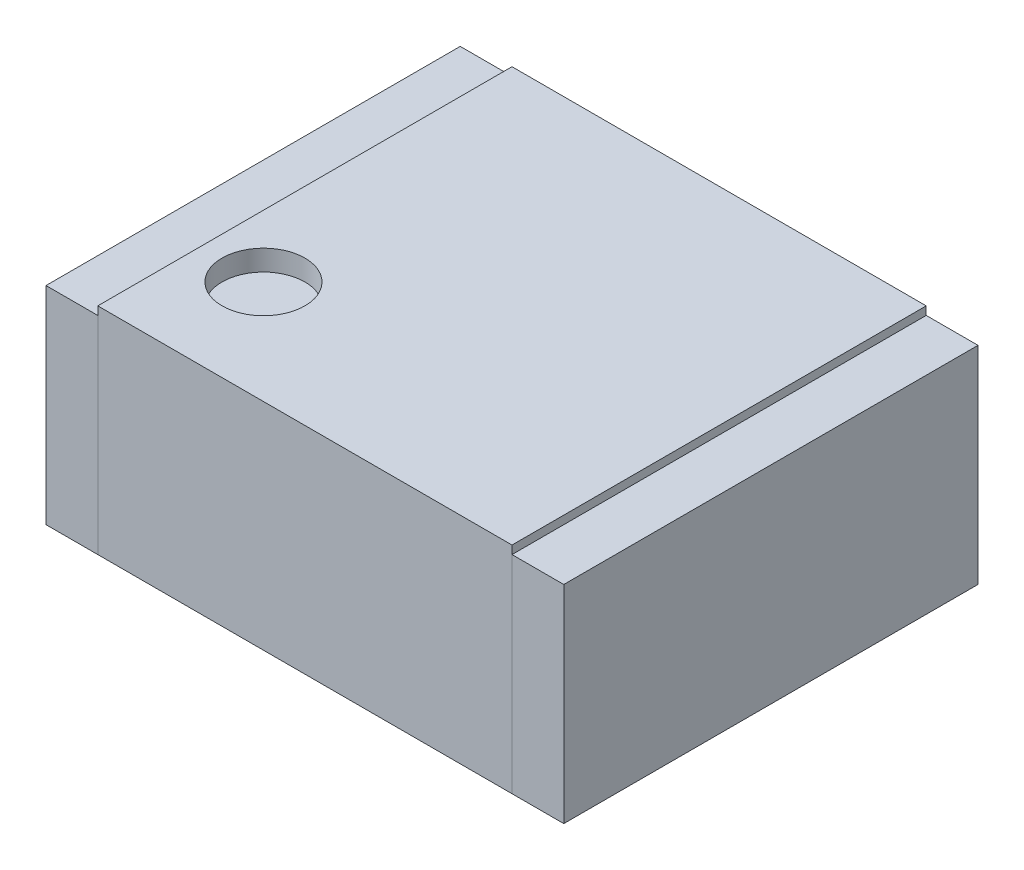
from build123d import *

# Parameters (mm, degrees)
SKETCH1_W             = 2
SKETCH1_H             = 2
BOSS_EXTRUDE1_DEPTH   = 1.04
SKETCH3_W             = 0.25
SKETCH3_H             = 2
BOSS_EXTRUDE2_DEPTH   = 1
BOSS_EXTRUDE2_2_DEPTH = 1
SKETCH4_R             = 0.2
CUT_EXTRUDE1_DEPTH    = 0.1
BOSS_EXTRUDE3_START   = 0.01
BOSS_EXTRUDE3_DEPTH   = 0.1
SKETCH5_W             = 0.3
SKETCH5_H             = 0.2
BOSS_EXTRUDE3_2_DEPTH = 0.1
BOSS_EXTRUDE3_3_DEPTH = 0.1
BOSS_EXTRUDE3_4_DEPTH = 0.1
BOSS_EXTRUDE3_5_DEPTH = 0.1
BOSS_EXTRUDE3_6_DEPTH = 0.1
BOSS_EXTRUDE3_7_DEPTH = 0.1


with BuildPart() as part:
    # Sketch1 → Boss-Extrude1 (new body)
    with BuildSketch(Plane(origin=(0, 0, 0), x_dir=(1, 0, 0), z_dir=(0, 1, 0))):
        Rectangle(SKETCH1_W, SKETCH1_H)
    extrude(amount=BOSS_EXTRUDE1_DEPTH)

    # Sketch4 → Cut-Extrude1 (cut)
    with BuildSketch(Plane(origin=(0, 1.04, 0), x_dir=(1, 0, 0), z_dir=(0, 1, 0))):
        with Locations((-0.7, -0.5)):
            Circle(SKETCH4_R)
    extrude(amount=-CUT_EXTRUDE1_DEPTH, mode=Mode.SUBTRACT)


with BuildPart() as body_2:
    # Sketch3 → Boss-Extrude2 (new body)
    with BuildSketch(Plane(origin=(0, 0, 0), x_dir=(1, 0, 0), z_dir=(0, 1, 0))):
        with Locations((-1.125, 0)):
            Rectangle(SKETCH3_W, SKETCH3_H)
    extrude(amount=BOSS_EXTRUDE2_DEPTH)


with BuildPart() as body_3:
    # Sketch3 → Boss-Extrude2 2 (new body)
    with BuildSketch(Plane(origin=(0, 0, 0), x_dir=(1, 0, 0), z_dir=(0, 1, 0))):
        with Locations((1.125, 0)):
            Rectangle(SKETCH3_W, SKETCH3_H)
    extrude(amount=BOSS_EXTRUDE2_2_DEPTH)


with BuildPart() as body_4:
    # Sketch5 → Boss-Extrude3 (new body)
    with BuildSketch(Plane.XZ.offset(BOSS_EXTRUDE3_START)):
        Polygon((-0.75, 0.45), (-0.65, 0.55), (0.75, 0.55), (0.75, -0.55), (-0.75, -0.55), align=None)
    extrude(amount=-BOSS_EXTRUDE3_DEPTH)


with BuildPart() as body_5:
    # Sketch5 → Boss-Extrude3 2 (new body)
    with BuildSketch(Plane.XZ.offset(BOSS_EXTRUDE3_START)):
        with Locations((0.55, -0.85)):
            Rectangle(SKETCH5_W, SKETCH5_H)
    extrude(amount=-BOSS_EXTRUDE3_2_DEPTH)


with BuildPart() as body_6:
    # Sketch5 → Boss-Extrude3 3 (new body)
    with BuildSketch(Plane.XZ.offset(BOSS_EXTRUDE3_START)):
        with Locations((0, -0.85)):
            Rectangle(SKETCH5_W, SKETCH5_H)
    extrude(amount=-BOSS_EXTRUDE3_3_DEPTH)


with BuildPart() as body_7:
    # Sketch5 → Boss-Extrude3 4 (new body)
    with BuildSketch(Plane.XZ.offset(BOSS_EXTRUDE3_START)):
        with Locations((-0.55, -0.85)):
            Rectangle(SKETCH5_W, SKETCH5_H)
    extrude(amount=-BOSS_EXTRUDE3_4_DEPTH)


with BuildPart() as body_8:
    # Sketch5 → Boss-Extrude3 5 (new body)
    with BuildSketch(Plane.XZ.offset(BOSS_EXTRUDE3_START)):
        with Locations((-0.55, 0.85)):
            Rectangle(SKETCH5_W, SKETCH5_H)
    extrude(amount=-BOSS_EXTRUDE3_5_DEPTH)


with BuildPart() as body_9:
    # Sketch5 → Boss-Extrude3 6 (new body)
    with BuildSketch(Plane.XZ.offset(BOSS_EXTRUDE3_START)):
        with Locations((0.55, 0.85)):
            Rectangle(SKETCH5_W, SKETCH5_H)
    extrude(amount=-BOSS_EXTRUDE3_6_DEPTH)


with BuildPart() as body_10:
    # Sketch5 → Boss-Extrude3 7 (new body)
    with BuildSketch(Plane.XZ.offset(BOSS_EXTRUDE3_START)):
        with Locations((0, 0.85)):
            Rectangle(SKETCH5_W, SKETCH5_H)
    extrude(amount=-BOSS_EXTRUDE3_7_DEPTH)


solid = Compound([part.part, body_2.part, body_3.part, body_4.part, body_5.part, body_6.part, body_7.part, body_8.part, body_9.part, body_10.part])
